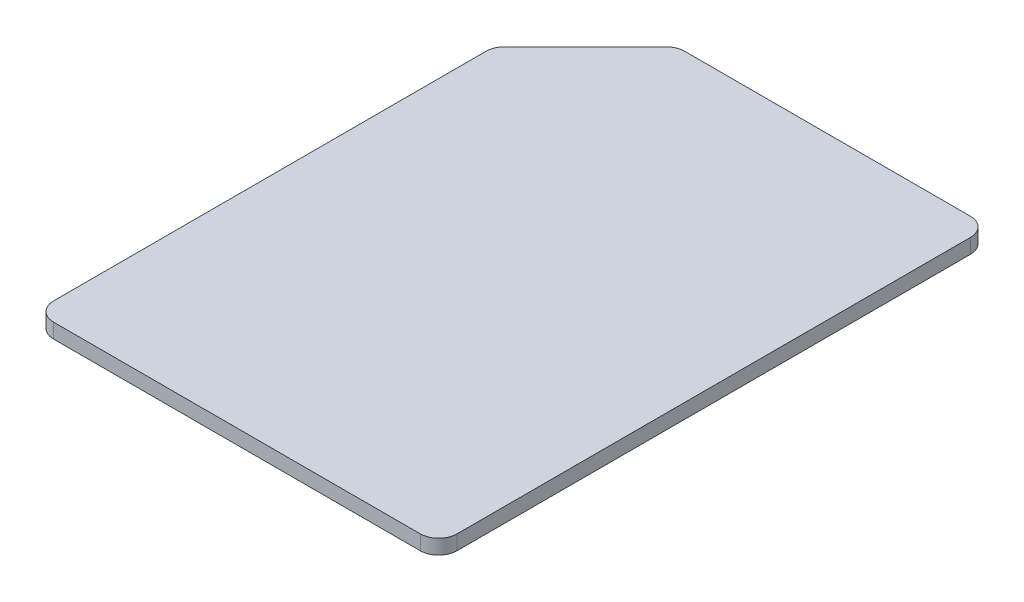
from build123d import *

# Parameters (mm, degrees)
SKETCH1_W           = 11
SKETCH1_H           = 15
BOSS_EXTRUDE1_DEPTH = 0.4
CHAMFER1_SIZE       = 2.5
FILLET1_R           = 0.5


with BuildPart() as part:
    # Sketch1 → Boss-Extrude1 (new body)
    with BuildSketch(Plane(origin=(0, 0, 0), x_dir=(1, 0, 0), z_dir=(0, 1, 0))):
        Rectangle(SKETCH1_W, SKETCH1_H)
    extrude(amount=BOSS_EXTRUDE1_DEPTH)

    # Chamfer1
    chamfer1_edges = [part.edges().sort_by_distance(p)[0] for p in [
        (-5.5, 0.2, -7.5),
    ]]
    chamfer(chamfer1_edges, length=CHAMFER1_SIZE)

    # Fillet1
    fillet1_edges = [part.edges().sort_by_distance(p)[0] for p in [
        (-5.5, 0.2, -5),
        (-3, 0.2, -7.5),
        (5.5, 0.2, 7.5),
        (-5.5, 0.2, 7.5),
        (5.5, 0.2, -7.5),
    ]]
    fillet(fillet1_edges, radius=FILLET1_R)


solid = part.part
